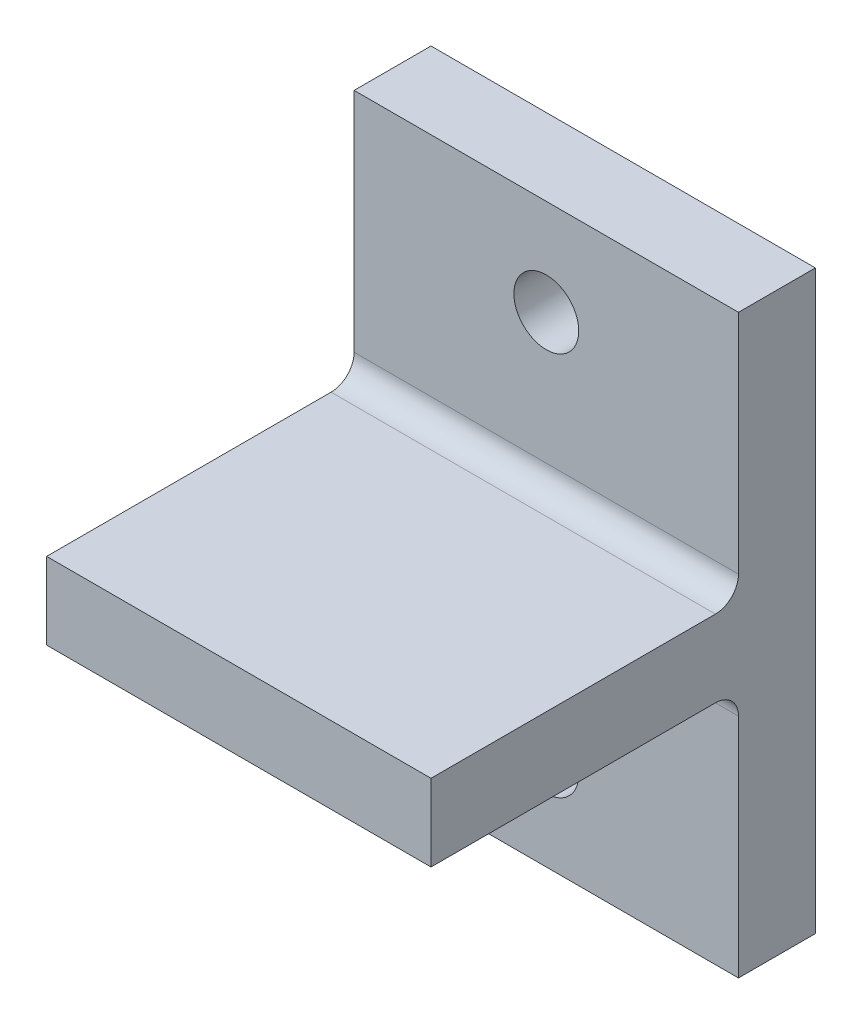
from build123d import *

# Parameters (mm, degrees)
CROQUIS1_W                     = 50
CROQUIS1_H                     = 75
SALIENTE_EXTRUIR1_DEPTH        = 10
CROQUIS2_W                     = 50
CROQUIS2_H                     = 10
SALIENTE_EXTRUIR2_DEPTH        = 40
REDONDEO1_R                    = 3
TALADRO_DE_MARGEN_PARA_5_161_D = 8.4328


with BuildPart() as part:
    # Croquis1 → Saliente-Extruir1 (new body)
    with BuildSketch(Plane.XY):
        Rectangle(CROQUIS1_W, CROQUIS1_H)
    extrude(amount=SALIENTE_EXTRUIR1_DEPTH)

    # Croquis2 → Saliente-Extruir2 (add)
    with BuildSketch(Plane.XY.offset(10)):
        Rectangle(CROQUIS2_W, CROQUIS2_H)
    extrude(amount=SALIENTE_EXTRUIR2_DEPTH)

    # Redondeo1
    redondeo1_edges = [part.edges().sort_by_distance(p)[0] for p in [
        (0, -5, 10),
        (0, 5, 10),
    ]]
    fillet(redondeo1_edges, radius=REDONDEO1_R)

    # Taladro de margen para 5/161 (through all)
    with Locations(Plane(origin=(0, 25, 0), x_dir=(-1, 0, 0), z_dir=(0, 0, -1))):
        with Locations((0, 0), (0, -50)):
            Hole(TALADRO_DE_MARGEN_PARA_5_161_D / 2)


solid = part.part
